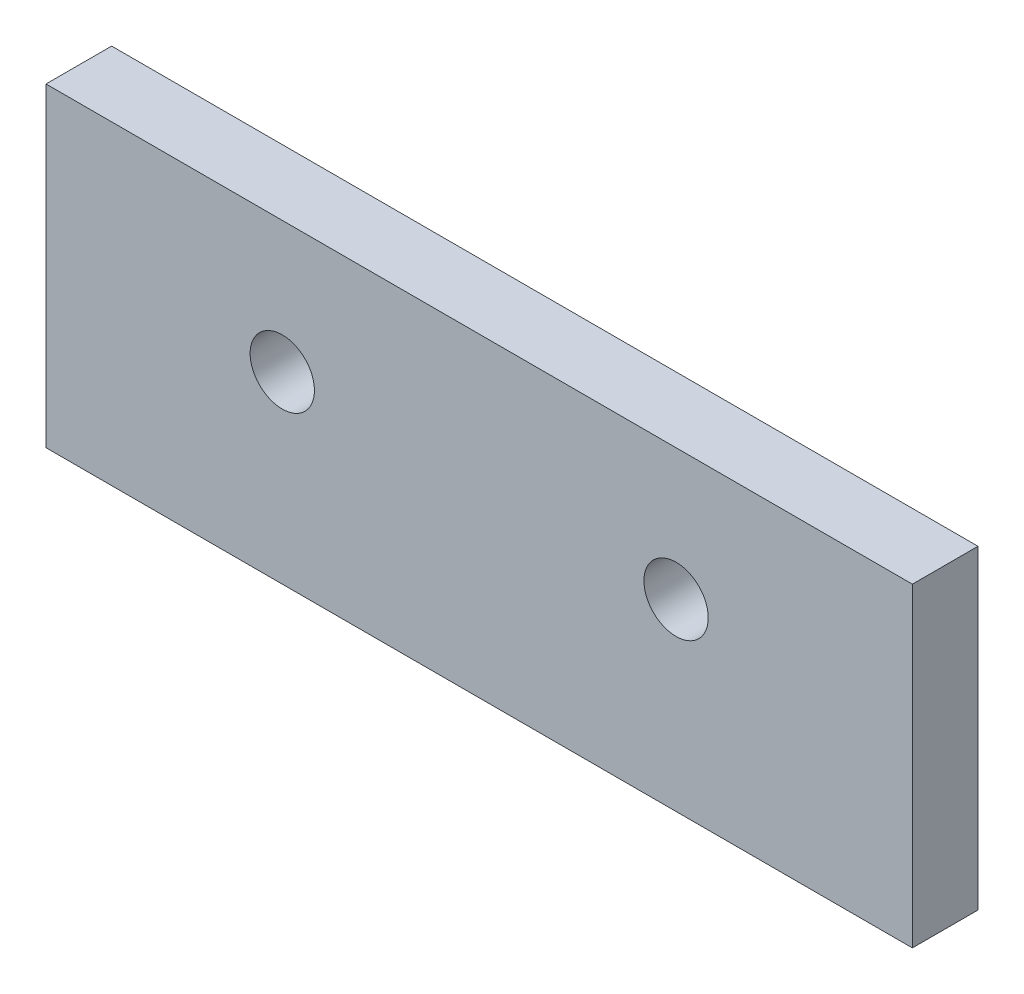
from build123d import *

# Parameters (mm, degrees)
SKETCH2_W           = 66
SKETCH2_H           = 24
SKETCH2_R           = 2.45
BOSS_EXTRUDE1_DEPTH = 5


with BuildPart() as part:
    # Sketch2 → Boss-Extrude1 (new body)
    with BuildSketch(Plane.XY):
        with Locations((10.516483516, -12)):
            Rectangle(SKETCH2_W, SKETCH2_H)
        with Locations((-4.483516484, -10)):
            Circle(SKETCH2_R, mode=Mode.SUBTRACT)
        with Locations((25.516483516, -10)):
            Circle(SKETCH2_R, mode=Mode.SUBTRACT)
    extrude(amount=BOSS_EXTRUDE1_DEPTH)


solid = part.part
